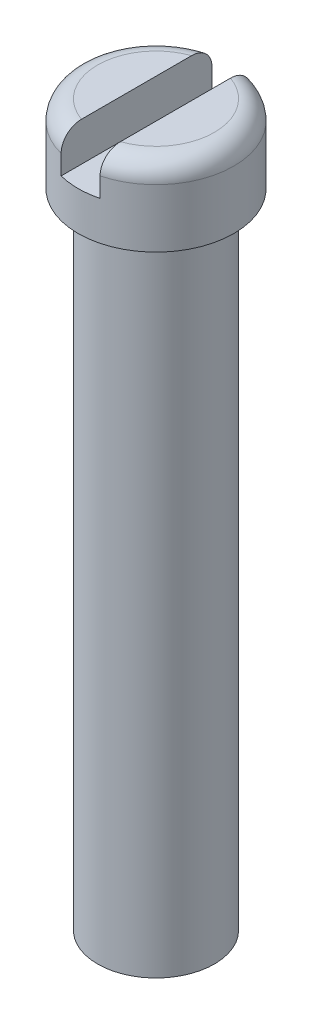
from build123d import *

# Parameters (mm, degrees)
ESQUISSE1_R             = 1.5
BOSS_EXTRU_1_DEPTH      = 16.5
ESQUISSE2_R             = 2
BOSS_EXTRU_2_DEPTH      = 2
ESQUISSE3_W             = 1
ESQUISSE3_H             = 4
ENL_V_MAT_EXTRU_1_DEPTH = 1
CONG_1_R                = 0.5


with BuildPart() as part:
    # Esquisse1 → Boss.-Extru.1 (new body)
    with BuildSketch(Plane(origin=(0, 0, 0), x_dir=(1, 0, 0), z_dir=(0, 1, 0))):
        Circle(ESQUISSE1_R)
    extrude(amount=BOSS_EXTRU_1_DEPTH)

    # Esquisse2 → Boss.-Extru.2 (add)
    with BuildSketch(Plane(origin=(0, 16.5, 0), x_dir=(1, 0, 0), z_dir=(0, 1, 0))):
        Circle(ESQUISSE2_R)
    extrude(amount=BOSS_EXTRU_2_DEPTH)

    # Esquisse3 → Enlèv. mat.-Extru.1 (cut)
    with BuildSketch(Plane(origin=(0, 18.5, 0), x_dir=(1, 0, 0), z_dir=(0, 1, 0))):
        Rectangle(ESQUISSE3_W, ESQUISSE3_H)
    extrude(amount=-ENL_V_MAT_EXTRU_1_DEPTH, mode=Mode.SUBTRACT)

    # Congé1
    cong_1_edges = [part.edges().sort_by_distance(p)[0] for p in [
        (1.58113883, 18.5, -1.224744871),
        (-2, 18.5, 0),
    ]]
    fillet(cong_1_edges, radius=CONG_1_R)


solid = part.part
